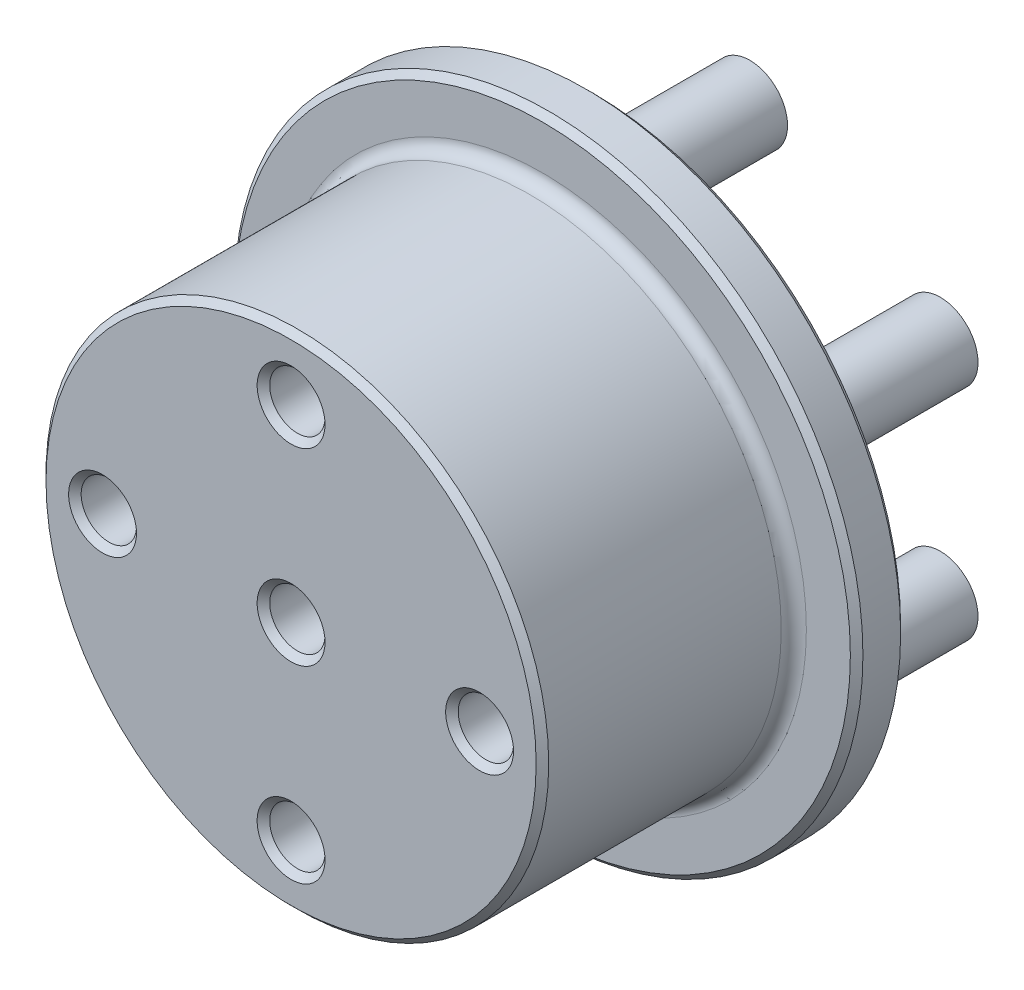
from build123d import *

# Parameters (mm, degrees)
SKETCH1_R                 = 25
BOSS_EXTRUDE1_DEPTH       = 4
SKETCH2_R                 = 20
BOSS_EXTRUDE2_DEPTH       = 20
FILLET1_R                 = 1
SKETCH3_R                 = 10.2
CUT_EXTRUDE1_DEPTH        = 5
SKETCH4_R                 = 3
BOSS_EXTRUDE3_DEPTH       = 12.5
F_4_0MM_DOWEL_HOLE1_D     = 4.4
F_4_0MM_DOWEL_HOLE1_DEPTH = 8
F_4_0MM_DOWEL_HOLE1_TIP   = 1.321893362
FILLET2_R                 = 1
CHAMFER1_SIZE             = 0.5


with BuildPart() as part:
    # Sketch1 → Boss-Extrude1 (new body)
    with BuildSketch(Plane.XY):
        Circle(SKETCH1_R)
    extrude(amount=-BOSS_EXTRUDE1_DEPTH)

    # Sketch2 → Boss-Extrude2 (add)
    with BuildSketch(Plane.XY):
        Circle(SKETCH2_R)
    extrude(amount=BOSS_EXTRUDE2_DEPTH)

    # Fillet1
    fillet1_edges = [part.edges().sort_by_distance(p)[0] for p in [
        (-20, 0, 0),
    ]]
    fillet(fillet1_edges, radius=FILLET1_R)

    # Sketch3 → Cut-Extrude1 (cut)
    with BuildSketch(Plane(origin=(0, 0, -4), x_dir=(-1, 0, 0), z_dir=(0, 0, -1))):
        Circle(SKETCH3_R)
    extrude(amount=-CUT_EXTRUDE1_DEPTH, mode=Mode.SUBTRACT)

    # Sketch4 → Boss-Extrude3 (add)
    with BuildSketch(Plane(origin=(0, 0, -4), x_dir=(-1, 0, 0), z_dir=(0, 0, -1))):
        with Locations((0, 17.5)):
            Circle(SKETCH4_R)
        with Locations((15.155444566, 8.75)):
            Circle(SKETCH4_R)
        with Locations((15.155444566, -8.75)):
            Circle(SKETCH4_R)
        with Locations((0, -17.5)):
            Circle(SKETCH4_R)
        with Locations((-15.155444566, -8.75)):
            Circle(SKETCH4_R)
        with Locations((-15.155444566, 8.75)):
            Circle(SKETCH4_R)
    extrude(amount=BOSS_EXTRUDE3_DEPTH)

    # Ø4.0mm Dowel Hole1
    with Locations(Plane.XY.offset(20)):
        with Locations((0, 0), (0, 15), (15, 0), (0, -15), (-15, 0)):
            Hole(F_4_0MM_DOWEL_HOLE1_D / 2, depth=F_4_0MM_DOWEL_HOLE1_DEPTH)
            with Locations((0, 0, -(F_4_0MM_DOWEL_HOLE1_DEPTH + F_4_0MM_DOWEL_HOLE1_TIP / 2))):  # 118° drill point
                Cone(0, F_4_0MM_DOWEL_HOLE1_D / 2, F_4_0MM_DOWEL_HOLE1_TIP, mode=Mode.SUBTRACT)

    # Fillet2
    fillet2_edges = [part.edges().sort_by_distance(p)[0] for p in [
        (-12.155444566, 8.75, -4),
        (-12.155444566, -8.75, -4),
        (3, -17.5, -4),
        (18.155444566, 8.75, -4),
        (3, 17.5, -4),
        (18.155444566, -8.75, -4),
    ]]
    fillet(fillet2_edges, radius=FILLET2_R)

    # Chamfer1
    chamfer1_edges = [part.edges().sort_by_distance(p)[0] for p in [
        (10.2, 0, 1),
        (10.2, 0, -4),
        (-25, 0, 0),
        (-12.8, 0, 20),
        (-25, 0, -4),
        (2.2, -15, 20),
        (17.2, 0, 20),
        (2.2, 15, 20),
        (2.2, 0, 20),
        (-20, 0, 20),
    ]]
    chamfer(chamfer1_edges, length=CHAMFER1_SIZE)


solid = part.part
